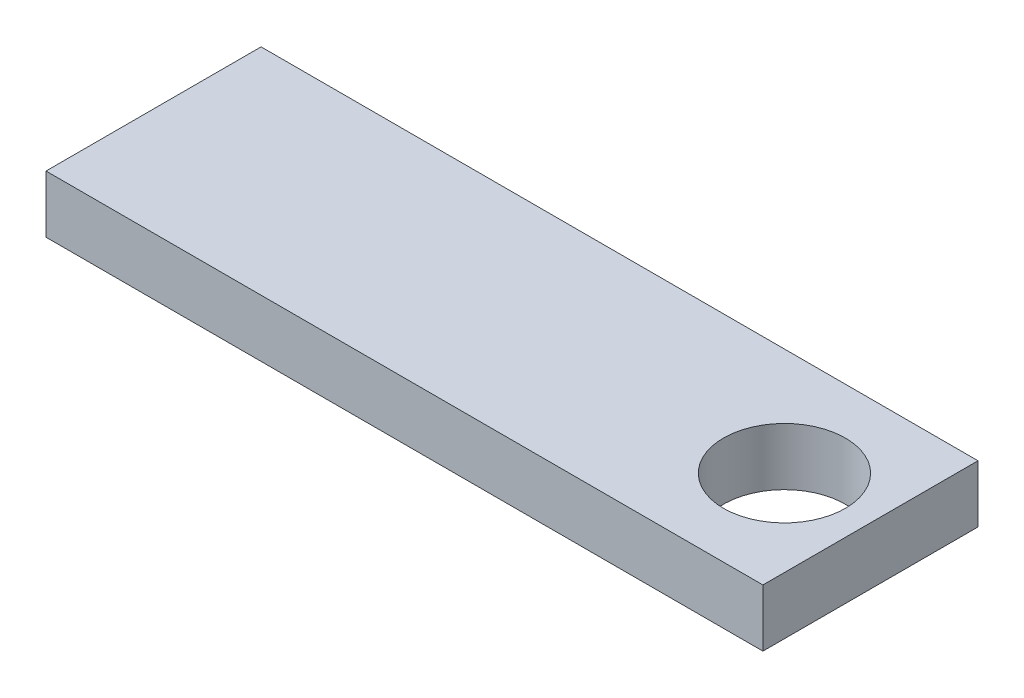
from build123d import *

# Parameters (mm, degrees)
SKETCH1_W           = 50
SKETCH1_H           = 15
BOSS_EXTRUDE1_DEPTH = 4
SKETCH2_R           = 4.25
CUT_EXTRUDE1_DEPTH  = 5


with BuildPart() as part:
    # Sketch1 → Boss-Extrude1 (new body)
    with BuildSketch(Plane(origin=(0, 0, 0), x_dir=(1, 0, 0), z_dir=(0, 1, 0))):
        Rectangle(SKETCH1_W, SKETCH1_H)
    extrude(amount=BOSS_EXTRUDE1_DEPTH)

    # Sketch2 → Cut-Extrude1 (cut, through all)
    with BuildSketch(Plane(origin=(0, 4, 0), x_dir=(1, 0, 0), z_dir=(0, 1, 0))):
        with Locations((19, 0)):
            Circle(SKETCH2_R)
    extrude(amount=-CUT_EXTRUDE1_DEPTH, mode=Mode.SUBTRACT)


solid = part.part
